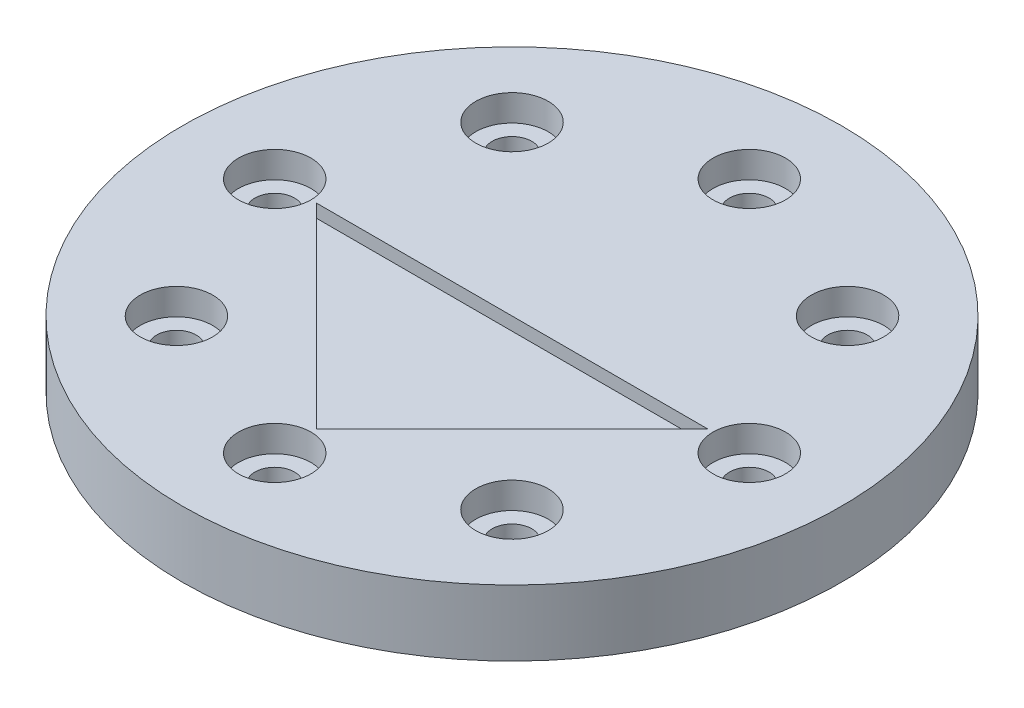
from build123d import *

# Parameters (mm, degrees)
SKETCH_1_R               = 25
EXTRUDE_2_DEPTH          = 1
SKETCH_2_R               = 1.5
CUT_EXTRUDE_1_DEPTH      = 1
PATTERN_CIRCULAR_1_COUNT = 8
CUT_EXTRUDE_2_DEPTH      = 1
EXTRUDE_3_DEPTH          = 1
SKETCH_5_R               = 25
EXTRUDE_5_DEPTH          = 2
SKETCH_6_R               = 1.5
CUT_EXTRUDE_3_DEPTH      = 2
PATTERN_CIRCULAR_2_COUNT = 8
SKETCH_7_R               = 25
EXTRUDE_6_DEPTH          = 2
SKETCH_8_R               = 2.75
CUT_EXTRUDE_4_DEPTH      = 2
PATTERN_CIRCULAR_3_COUNT = 8
EXTRUDE_8_DEPTH          = 2


with BuildPart() as part:
    # 草图1 → 凸台-拉伸2 (new body)
    with BuildSketch(Plane(origin=(0, 0, 0), x_dir=(1, 0, 0), z_dir=(0, 1, 0))):
        Circle(SKETCH_1_R)
    extrude(amount=EXTRUDE_2_DEPTH)

    # 草图2 → 切除-拉伸1 (cut)
    with BuildSketch(Plane(origin=(0, 1, 0), x_dir=(1, 0, 0), z_dir=(0, 1, 0))):
        with Locations((18, 0)):
            Circle(SKETCH_2_R)
    cut_extrude_1 = extrude(amount=-CUT_EXTRUDE_1_DEPTH, mode=Mode.SUBTRACT)

    # 阵列(圆周)1: 切除-拉伸1 ×8 about axis
    pattern_circular_1_axis = Axis((0, 0, 0), (0, 1, 0))
    for i in range(1, PATTERN_CIRCULAR_1_COUNT):
        add(cut_extrude_1.rotate(pattern_circular_1_axis, i * 360 / PATTERN_CIRCULAR_1_COUNT), mode=Mode.SUBTRACT)

    # 草图3 → 切除-拉伸2 (cut)
    with BuildSketch(Plane(origin=(0, 1, 0), x_dir=(1, 0, 0), z_dir=(0, 1, 0))):
        Polygon((-15.202795796, 0), (15.202795796, 0), (0, -15.202795796), align=None)
    extrude(amount=-CUT_EXTRUDE_2_DEPTH, mode=Mode.SUBTRACT)

    # 草图4 → 凸台-拉伸3 (add)
    with BuildSketch(Plane(origin=(0, 1, 0), x_dir=(1, 0, 0), z_dir=(0, 1, 0))):
        Polygon((0, -14.849242405), (14.849242405, 0), (15.202795796, 0), (0, -15.202795796), (-15.202795796, 0), (-14.849242405, 0), align=None)
    extrude(amount=-EXTRUDE_3_DEPTH)

    # 草图5 → 凸台-拉伸5 (add)
    with BuildSketch(Plane.XZ):
        Circle(SKETCH_5_R)
    extrude(amount=EXTRUDE_5_DEPTH)

    # 草图6 → 切除-拉伸3 (cut)
    with BuildSketch(Plane(origin=(0, 0, 0), x_dir=(1, 0, 0), z_dir=(0, 1, 0))):
        with Locations((18, 0)):
            Circle(SKETCH_6_R)
    cut_extrude_3 = extrude(amount=-CUT_EXTRUDE_3_DEPTH, mode=Mode.SUBTRACT)

    # 阵列(圆周)2: 切除-拉伸3 ×8 about axis
    pattern_circular_2_axis = Axis((0, 1, 0), (0, -1, 0))
    for i in range(1, PATTERN_CIRCULAR_2_COUNT):
        add(cut_extrude_3.rotate(pattern_circular_2_axis, i * 360 / PATTERN_CIRCULAR_2_COUNT), mode=Mode.SUBTRACT)

    # 草图7 → 凸台-拉伸6 (add)
    with BuildSketch(Plane(origin=(0, 1, 0), x_dir=(1, 0, 0), z_dir=(0, 1, 0))):
        Circle(SKETCH_7_R)
        Polygon((-14.849242405, 0), (14.849242405, 0), (0, -14.849242405), align=None, mode=Mode.SUBTRACT)
    extrude(amount=EXTRUDE_6_DEPTH)

    # 草图8 → 切除-拉伸4 (cut)
    with BuildSketch(Plane(origin=(0, 1, 0), x_dir=(1, 0, 0), z_dir=(0, 1, 0))):
        with Locations((18, 0)):
            Circle(SKETCH_8_R)
    cut_extrude_4 = extrude(amount=CUT_EXTRUDE_4_DEPTH, mode=Mode.SUBTRACT)

    # 阵列(圆周)3: 切除-拉伸4 ×8 about axis
    pattern_circular_3_axis = Axis((0, 0, 0), (0, 1, 0))
    for i in range(1, PATTERN_CIRCULAR_3_COUNT):
        add(cut_extrude_4.rotate(pattern_circular_3_axis, i * 360 / PATTERN_CIRCULAR_3_COUNT), mode=Mode.SUBTRACT)

    # 草图9 → 凸台-拉伸8 (add)
    with BuildSketch(Plane(origin=(0, 0, 0), x_dir=(1, 0, 0), z_dir=(0, 1, 0))):
        Polygon((-14.849242405, 0), (14.849242405, 0), (0, -14.849242405), align=None)
    extrude(amount=EXTRUDE_8_DEPTH)


solid = part.part
